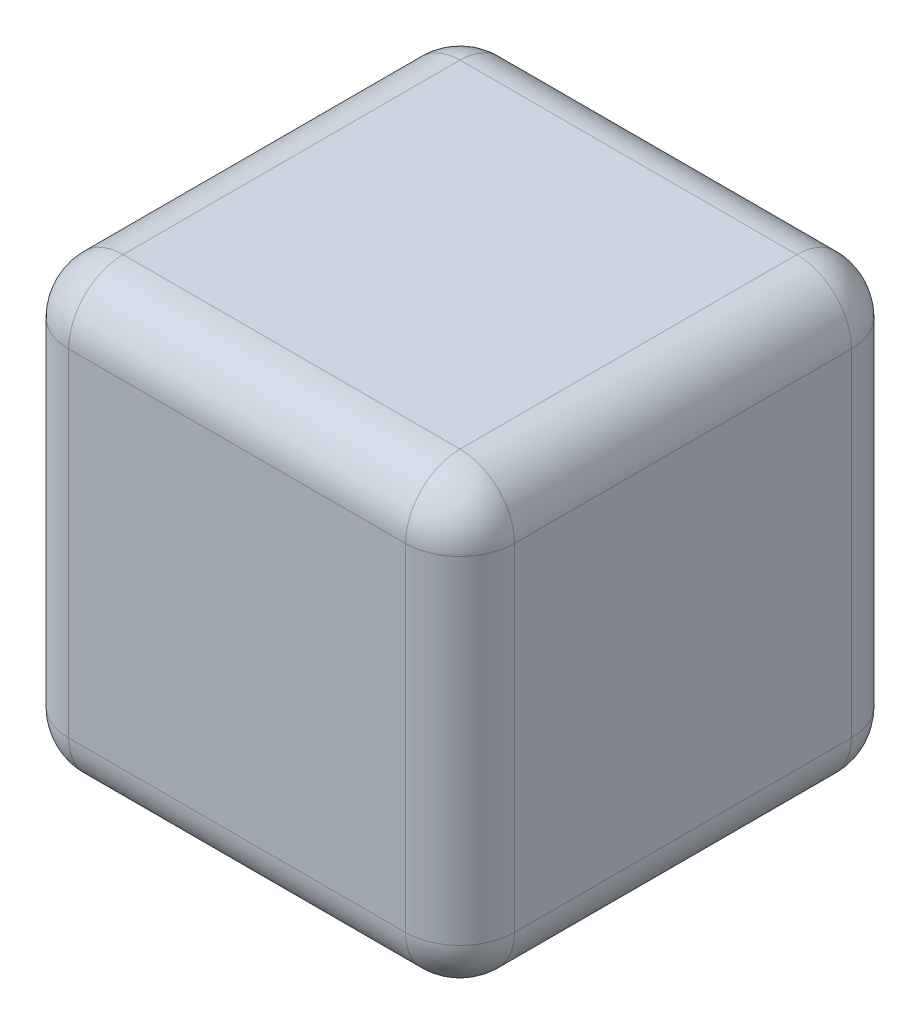
from build123d import *

# Parameters (mm, degrees)
SKETCH1_W           = 90
SKETCH1_H           = 90
BOSS_EXTRUDE1_DEPTH = 90
FILLET1_R           = 11


with BuildPart() as part:
    # Sketch1 → Boss-Extrude1 (new body)
    with BuildSketch(Plane(origin=(0, 0, 0), x_dir=(1, 0, 0), z_dir=(0, 1, 0))):
        Rectangle(SKETCH1_W, SKETCH1_H)
    extrude(amount=BOSS_EXTRUDE1_DEPTH)

    # Fillet1
    fillet1_edges = [part.edges().sort_by_distance(p)[0] for p in [
        (-45, 90, 0),
        (0, 90, 45),
        (45, 90, 0),
        (0, 0, 45),
        (-45, 0, 0),
        (0, 0, -45),
        (45, 0, 0),
        (0, 90, -45),
        (45, 45, 45),
        (-45, 45, 45),
        (-45, 45, -45),
        (45, 45, -45),
    ]]
    fillet(fillet1_edges, radius=FILLET1_R)


solid = part.part
